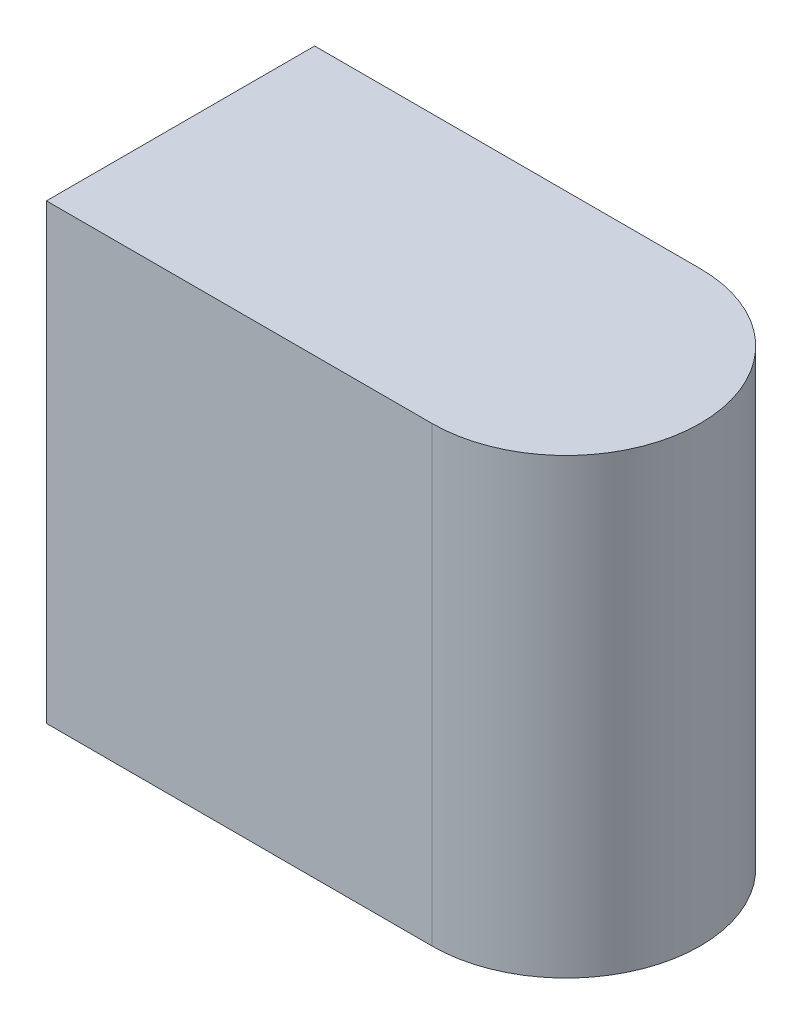
from build123d import *

# Parameters (mm, degrees)
P_IDAT_VYSUNUT_M1_DEPTH = 13.5


with BuildPart() as part:
    # Skica1 → Přidat vysunutím1 (new body)
    with BuildSketch(Plane(origin=(0, 0, 0), x_dir=(1, 0, 0), z_dir=(0, 1, 0))):
        with BuildLine():
            Line((0, 0), (0, 8))
            Line((0, 8), (11.5, 8))
            ThreePointArc((11.5, 8), (15.5, 4), (11.5, 0))
            Line((11.5, 0), (0, 0))
        make_face()
    extrude(amount=P_IDAT_VYSUNUT_M1_DEPTH)


solid = part.part
